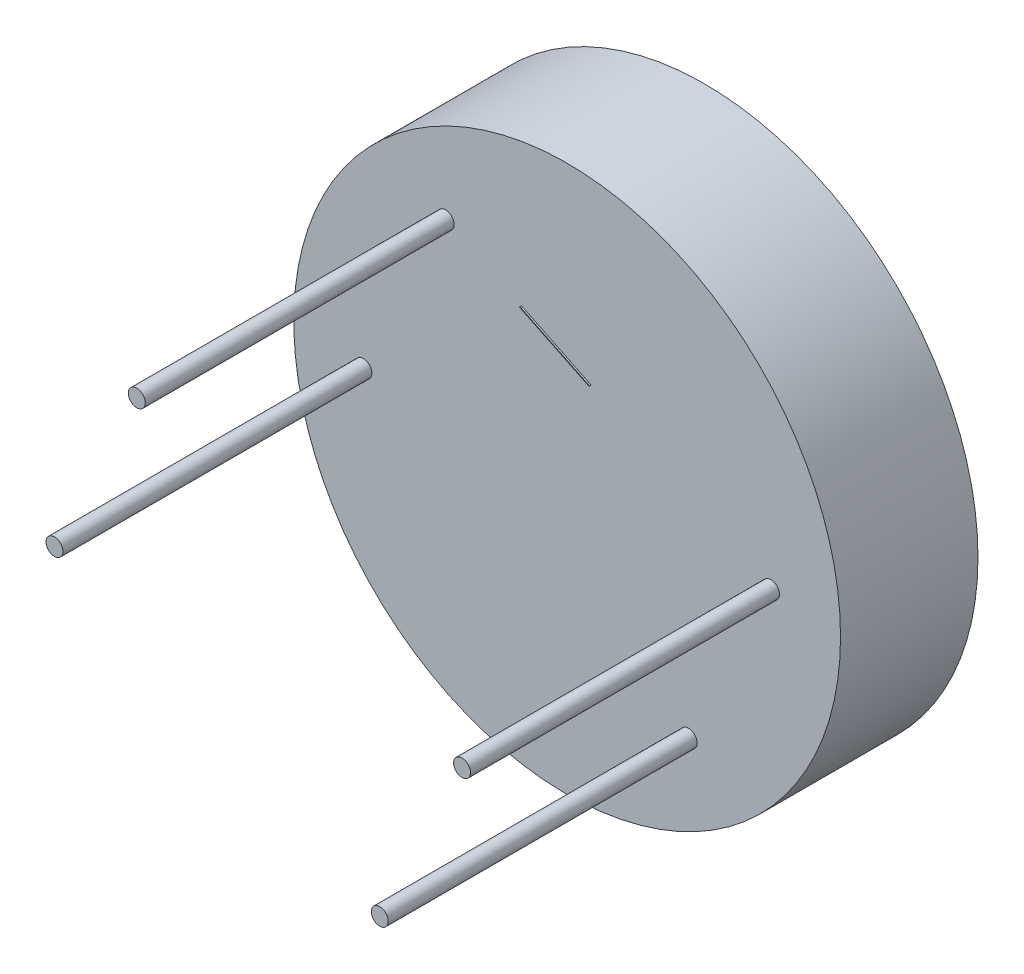
from build123d import *

# Parameters (mm, degrees)
ESQUISSE1_R        = 177
BOSS_EXTRU_1_DEPTH = 89
ESQUISSE2_R        = 5.5
BOSS_EXTRU_2_DEPTH = 200
BOSS_EXTRU_4_DEPTH = 1


with BuildPart() as part:
    # Esquisse1 → Boss.-Extru.1 (new body)
    with BuildSketch(Plane.XY):
        Circle(ESQUISSE1_R)
    extrude(amount=BOSS_EXTRU_1_DEPTH)

    # Esquisse2 → Boss.-Extru.2 (add)
    with BuildSketch(Plane.XY.offset(89)):
        with Locations((-131.939733982, -3.988307506)):
            Circle(ESQUISSE2_R)
        with Locations((78.648083604, -106.011692494)):
            Circle(ESQUISSE2_R)
        with Locations((131.939733982, 3.988307506)):
            Circle(ESQUISSE2_R)
        with Locations((-78.648083604, 106.011692494)):
            Circle(ESQUISSE2_R)
    extrude(amount=BOSS_EXTRU_2_DEPTH)

    # Esquisse4 → Boss.-Extru.4 (add)
    with BuildSketch(Plane.XY.offset(89)):
        Polygon((-29.640529762, 82.269024992), (-29.858528448, 81.819051023), (15.138868472, 60.019182436), (15.356867158, 60.469156405), align=None)
    extrude(amount=BOSS_EXTRU_4_DEPTH)


solid = part.part
